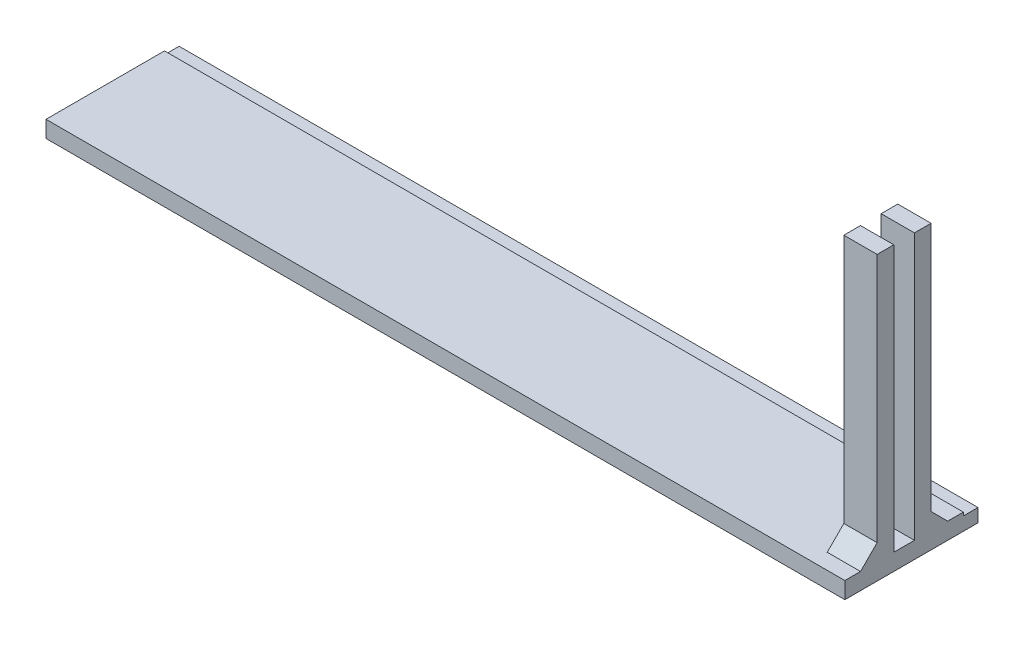
from build123d import *

# Parameters (mm, degrees)
SKETCH1_W           = 152.4
SKETCH1_H           = 25.4
BOSS_EXTRUDE1_DEPTH = 3.175
SKETCH2_W           = 152.4
SKETCH2_H           = 2.794
CUT_EXTRUDE1_DEPTH  = 0.635
SKETCH4_W           = 3.175
SKETCH4_H           = 50.8
BOSS_EXTRUDE2_DEPTH = 6.35
CHAMFER2_SIZE       = 3.175


with BuildPart() as part:
    # Sketch1 → Boss-Extrude1 (new body)
    with BuildSketch(Plane(origin=(0, 0, 0), x_dir=(1, 0, 0), z_dir=(0, 1, 0))):
        with Locations((76.2, 12.7)):
            Rectangle(SKETCH1_W, SKETCH1_H)
    extrude(amount=BOSS_EXTRUDE1_DEPTH)

    # Sketch2 → Cut-Extrude1 (cut)
    with BuildSketch(Plane(origin=(0, 3.175, 0), x_dir=(1, 0, 0), z_dir=(0, 1, 0))):
        with Locations((76.2, 24.003)):
            Rectangle(SKETCH2_W, SKETCH2_H)
    extrude(amount=-CUT_EXTRUDE1_DEPTH, mode=Mode.SUBTRACT)

    # Sketch4 → Boss-Extrude2 (add)
    with BuildSketch(Plane(origin=(152.4, 0, 0), x_dir=(0, 0, -1), z_dir=(1, 0, 0))):
        with Locations((7.747, 28.575)):
            Rectangle(SKETCH4_W, SKETCH4_H)
        with Locations((14.859, 28.575)):
            Rectangle(SKETCH4_W, SKETCH4_H)
    extrude(amount=-BOSS_EXTRUDE2_DEPTH)

    # Chamfer2
    chamfer2_edges = [part.edges().sort_by_distance(p)[0] for p in [
        (149.225, 3.175, -6.1595),
        (149.225, 3.175, -16.4465),
    ]]
    chamfer(chamfer2_edges, length=CHAMFER2_SIZE)


solid = part.part
